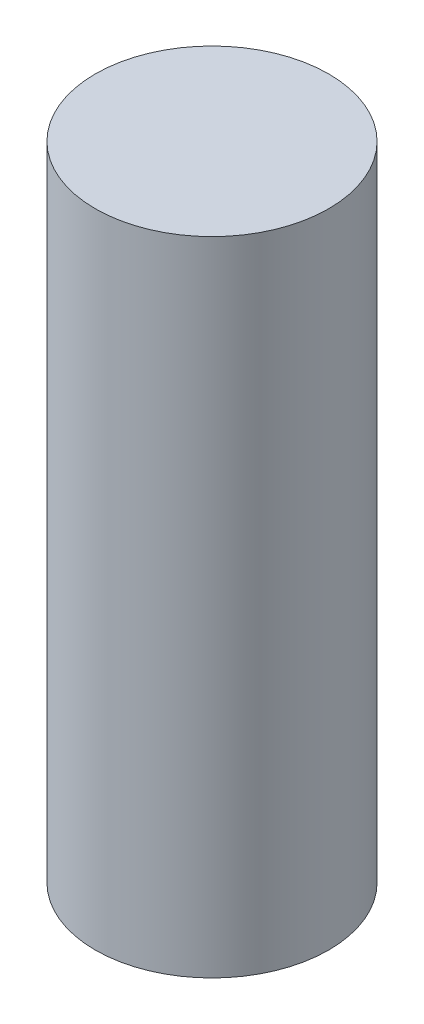
from build123d import *

# Parameters (mm, degrees)
SKETCH1_R           = 2
BOSS_EXTRUDE1_DEPTH = 11


with BuildPart() as part:
    # Sketch1 → Boss-Extrude1 (new body)
    with BuildSketch(Plane(origin=(0, 0, 0), x_dir=(1, 0, 0), z_dir=(0, 1, 0))):
        Circle(SKETCH1_R)
    extrude(amount=BOSS_EXTRUDE1_DEPTH)


solid = part.part
